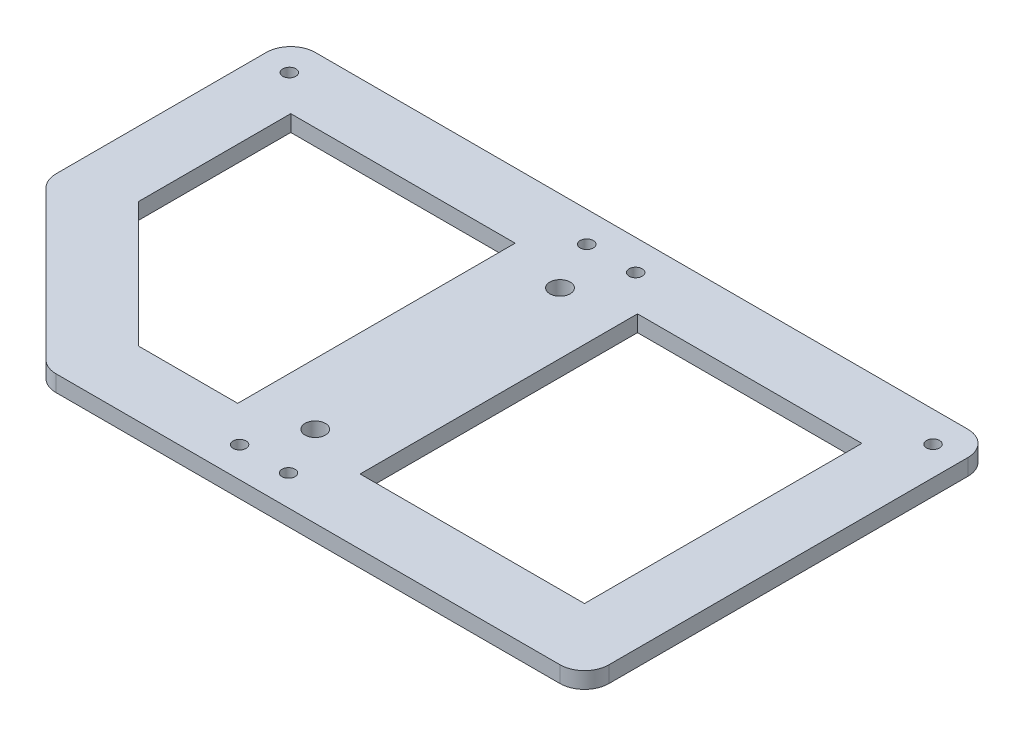
from build123d import *

# Parameters (mm, degrees)
SKIZZE1_W                       = 86
SKIZZE1_H                       = 50
AUFSATZ_LINEAR_AUSTRAGEN1_DEPTH = 2
F_1_6_1_6_DIAMETER_HOLE1_D      = 1.6
M3X0_5_GEWINDEBOHRUNG1_D        = 2.5
M3X0_5_GEWINDEBOHRUNG1_DEPTH    = 8.5
M3X0_5_GEWINDEBOHRUNG1_TIP      = 0.751075774
SKIZZE6_W                       = 27.5
SKIZZE6_H                       = 34
SCHNITT_LINEAR_AUSTRAGEN1_DEPTH = 3
FILLET1_R                       = 3
CUT_EXTRUDE1_REACH              = 4
SKETCH1_W                       = 20
SKETCH1_H                       = 20
BOSS_EXTRUDE1_DEPTH             = 2
FILLET2_R                       = 3


with BuildPart() as part:
    # Skizze1 → Aufsatz-Linear austragen1 (new body)
    with BuildSketch(Plane(origin=(0, 0, 0), x_dir=(1, 0, 0), z_dir=(0, 1, 0))):
        Rectangle(SKIZZE1_W, SKIZZE1_H)
    extrude(amount=AUFSATZ_LINEAR_AUSTRAGEN1_DEPTH)

    # Ø1.6 (1.6) Diameter Hole1 (through all)
    with Locations(Plane(origin=(0, 2, 0), x_dir=(1, 0, 0), z_dir=(0, 1, 0))):
        with Locations((-39.45, 21.275), (-3, 21.275), (-3, -21.275)):
            f_1_6_1_6_diameter_hole1 = Hole(F_1_6_1_6_DIAMETER_HOLE1_D / 2)

    # Spiegeln1: Ø1.6 (1.6) Diameter Hole1 across plane
    add(f_1_6_1_6_diameter_hole1.mirror(Plane(origin=(0, 0, 0), x_dir=(0, 0, 1), z_dir=(1, 0, 0))), mode=Mode.SUBTRACT)

    # M3x0.5 Gewindebohrung1
    with Locations(Plane(origin=(0, 2, 0), x_dir=(1, 0, 0), z_dir=(0, 1, 0))):
        with Locations((0, 15), (0, -15)):
            Hole(M3X0_5_GEWINDEBOHRUNG1_D / 2, depth=M3X0_5_GEWINDEBOHRUNG1_DEPTH)
            with Locations((0, 0, -(M3X0_5_GEWINDEBOHRUNG1_DEPTH + M3X0_5_GEWINDEBOHRUNG1_TIP / 2))):  # 118° drill point
                Cone(0, M3X0_5_GEWINDEBOHRUNG1_D / 2, M3X0_5_GEWINDEBOHRUNG1_TIP, mode=Mode.SUBTRACT)

    # Skizze6 → Schnitt-Linear austragen1 (cut, through all)
    with BuildSketch(Plane(origin=(0, 0, 0), x_dir=(1, 0, 0), z_dir=(0, 1, 0))):
        with Locations((-21.25, 0)):
            Rectangle(SKIZZE6_W, SKIZZE6_H)
        with Locations((21.25, 0)):
            Rectangle(SKIZZE6_W, SKIZZE6_H)
    extrude(amount=SCHNITT_LINEAR_AUSTRAGEN1_DEPTH, mode=Mode.SUBTRACT)

    # Fillet1
    fillet1_edges = [part.edges().sort_by_distance(p)[0] for p in [
        (-43, 1, -25),
        (43, 1, -25),
        (43, 1, 25),
        (-43, 1, 25),
    ]]
    fillet(fillet1_edges, radius=FILLET1_R)

    # Sketch1 → Cut-Extrude1 (cut, up to next)
    with BuildSketch(Plane(origin=(0, 2, 0), x_dir=(1, 0, 0), z_dir=(0, 1, 0)), mode=Mode.PRIVATE) as cut_extrude1_sk1:
        with Locations((-33, -15)):
            Rectangle(SKETCH1_W, SKETCH1_H)
    cut_extrude1_tool1 = extrude(cut_extrude1_sk1.sketch, amount=-CUT_EXTRUDE1_REACH, mode=Mode.PRIVATE) & part.part
    add(cut_extrude1_tool1.solids().sort_by_distance((-33, 2, 15))[0], mode=Mode.SUBTRACT)

    # Sketch2 → Boss-Extrude1 (add)
    with BuildSketch(Plane(origin=(0, 2, 0), x_dir=(1, 0, 0), z_dir=(0, 1, 0))):
        Polygon((-43, -5), (-23, -25), (-23, -17), (-19.686291501, -17), (-35, -1.686291501), (-35, -5), align=None)
    extrude(amount=-BOSS_EXTRUDE1_DEPTH)

    # Fillet2
    fillet2_edges = [part.edges().sort_by_distance(p)[0] for p in [
        (-43, 1, 5),
        (-23, 1, 25),
    ]]
    fillet(fillet2_edges, radius=FILLET2_R)


solid = part.part
